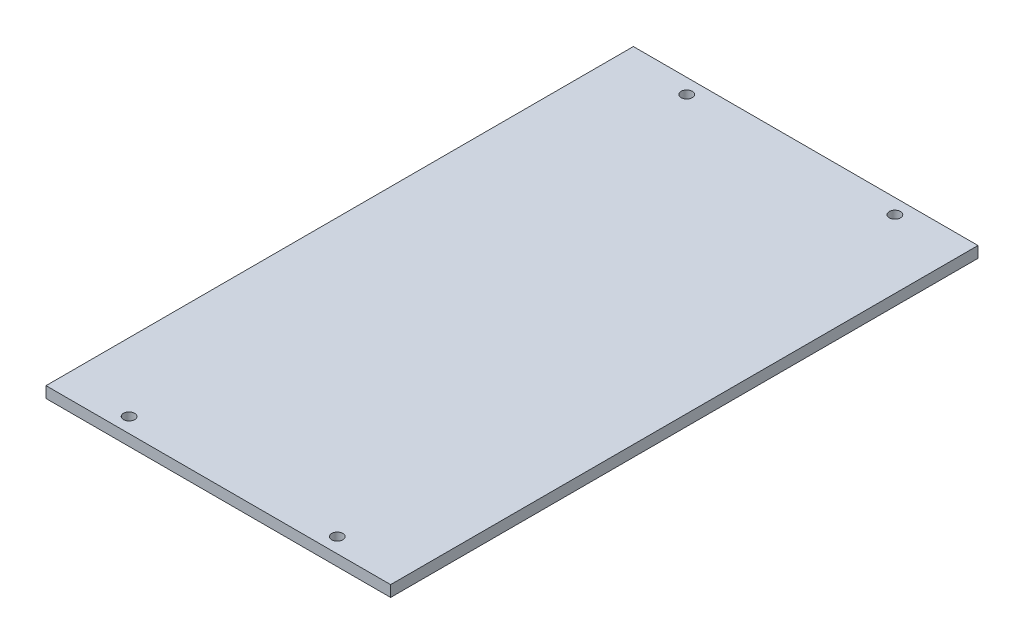
from build123d import *

# Parameters (mm, degrees)
SKETCH1_W           = 92.7
SKETCH1_H           = 158
SKETCH1_R           = 1.5
BOSS_EXTRUDE1_DEPTH = 3


with BuildPart() as part:
    # Sketch1 → Boss-Extrude1 (new body)
    with BuildSketch(Plane(origin=(0, 3, 0), x_dir=(1, 0, 0), z_dir=(0, 1, 0))):
        Rectangle(SKETCH1_W, SKETCH1_H)
        with Locations((28, -75)):
            Circle(SKETCH1_R, mode=Mode.SUBTRACT)
        with Locations((28, 75)):
            Circle(SKETCH1_R, mode=Mode.SUBTRACT)
        with Locations((-28, 75)):
            Circle(SKETCH1_R, mode=Mode.SUBTRACT)
        with Locations((-28, -75)):
            Circle(SKETCH1_R, mode=Mode.SUBTRACT)
    extrude(amount=-BOSS_EXTRUDE1_DEPTH)


solid = part.part
